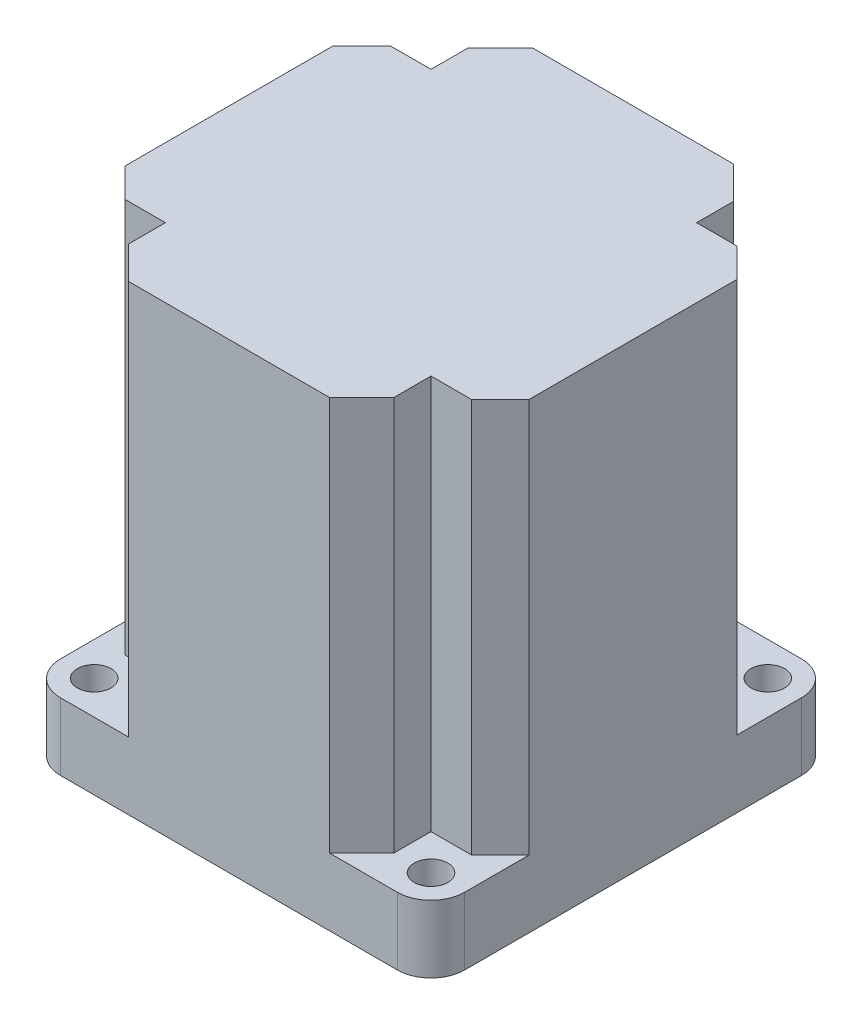
from build123d import *

# Parameters (mm, degrees)
SKETCH1_R           = 1.75
SKETCH1_R_2         = 14
BOSS_EXTRUDE1_DEPTH = 7
BOSS_EXTRUDE2_DEPTH = 34
BOSS_EXTRUDE3_DEPTH = 7
CUT_EXTRUDE1_START  = -41
CUT_EXTRUDE1_DEPTH  = 41
SKETCH1_2_R         = 14
CUT_EXTRUDE2_DEPTH  = 15


with BuildPart() as part:
    # Sketch1 → Boss-Extrude1 (new body)
    with BuildSketch(Plane(origin=(0, 0, 0), x_dir=(1, 0, 0), z_dir=(0, 1, 0))):
        with BuildLine():
            Line((17.5, -21), (-17.5, -21))
            ThreePointArc((-17.5, -21), (-19.974873734, -19.974873734), (-21, -17.5))
            Line((-21, -17.5), (-21, 17.5))
            ThreePointArc((-21, 17.5), (-19.974873734, 19.974873734), (-17.5, 21))
            Line((-17.5, 21), (17.5, 21))
            ThreePointArc((17.5, 21), (19.974873734, 19.974873734), (21, 17.5))
            Line((21, 17.5), (21, -17.5))
            ThreePointArc((21, -17.5), (19.974873734, -19.974873734), (17.5, -21))
        make_face()
        with Locations((-17.5, -17.5)):
            Circle(SKETCH1_R, mode=Mode.SUBTRACT)
        with Locations((-17.5, 17.5)):
            Circle(SKETCH1_R, mode=Mode.SUBTRACT)
        with Locations((17.5, -17.5)):
            Circle(SKETCH1_R, mode=Mode.SUBTRACT)
        with Locations((17.5, 17.5)):
            Circle(SKETCH1_R, mode=Mode.SUBTRACT)
        Circle(SKETCH1_R_2, mode=Mode.SUBTRACT)
    extrude(amount=BOSS_EXTRUDE1_DEPTH)

    # Sketch2 → Boss-Extrude2 (add)
    with BuildSketch(Plane(origin=(0, 7, 0), x_dir=(1, 0, 0), z_dir=(0, 1, 0))):
        with BuildLine():
            Line((21, -17.5), (21, 17.5))
            ThreePointArc((21, 17.5), (19.974873734, 19.974873734), (17.5, 21))
            Line((17.5, 21), (-17.5, 21))
            ThreePointArc((-17.5, 21), (-19.974873734, 19.974873734), (-21, 17.5))
            Line((-21, 17.5), (-21, -17.5))
            ThreePointArc((-21, -17.5), (-19.974873734, -19.974873734), (-17.5, -21))
            Line((-17.5, -21), (17.5, -21))
            ThreePointArc((17.5, -21), (19.974873734, -19.974873734), (21, -17.5))
        make_face()
    extrude(amount=BOSS_EXTRUDE2_DEPTH)

    # Sketch3 → Boss-Extrude3 (add)
    with BuildSketch(Plane(origin=(0, 41, 0), x_dir=(1, 0, 0), z_dir=(0, 1, 0))):
        with BuildLine():
            Line((17.5, 21), (-17.5, 21))
            ThreePointArc((-17.5, 21), (-19.974873734, 19.974873734), (-21, 17.5))
            Line((-21, 17.5), (-21, -17.5))
            ThreePointArc((-21, -17.5), (-19.974873734, -19.974873734), (-17.5, -21))
            Line((-17.5, -21), (17.5, -21))
            ThreePointArc((17.5, -21), (19.974873734, -19.974873734), (21, -17.5))
            Line((21, -17.5), (21, 17.5))
            ThreePointArc((21, 17.5), (19.974873734, 19.974873734), (17.5, 21))
        make_face()
    extrude(amount=BOSS_EXTRUDE3_DEPTH)

    # Sketch4 → Cut-Extrude1 (cut)
    with BuildSketch(Plane(origin=(0, 48, 0), x_dir=(1, 0, 0), z_dir=(0, 1, 0)).offset(CUT_EXTRUDE1_START)):
        with BuildLine():
            Line((-13.8, 13.8), (-18, 13.8))
            Line((-18, 13.8), (-21, 10.8))
            Line((-21, 10.8), (-21, 17.5))
            ThreePointArc((-21, 17.5), (-19.974873734, 19.974873734), (-17.5, 21))
            Line((-17.5, 21), (-10.45, 21))
            Line((-10.45, 21), (-13.8, 17.65))
            Line((-13.8, 17.65), (-13.8, 13.8))
        make_face()
        with BuildLine():
            Line((17.5, 21), (10.45, 21))
            Line((10.45, 21), (13.8, 17.65))
            Line((13.8, 17.65), (13.8, 13.8))
            Line((13.8, 13.8), (18, 13.8))
            Line((18, 13.8), (21, 10.8))
            Line((21, 10.8), (21, 17.5))
            ThreePointArc((21, 17.5), (19.974873734, 19.974873734), (17.5, 21))
        make_face()
        with BuildLine():
            Line((-17.5, -21), (-10.45, -21))
            Line((-10.45, -21), (-13.8, -17.65))
            Line((-13.8, -17.65), (-13.8, -13.8))
            Line((-13.8, -13.8), (-18, -13.8))
            Line((-18, -13.8), (-21, -10.8))
            Line((-21, -10.8), (-21, -17.5))
            ThreePointArc((-21, -17.5), (-19.974873734, -19.974873734), (-17.5, -21))
        make_face()
        with BuildLine():
            Line((21, -17.5), (21, -10.8))
            Line((21, -10.8), (18, -13.8))
            Line((18, -13.8), (13.8, -13.8))
            Line((13.8, -13.8), (13.8, -17.65))
            Line((13.8, -17.65), (10.45, -21))
            Line((10.45, -21), (17.5, -21))
            ThreePointArc((17.5, -21), (19.974873734, -19.974873734), (21, -17.5))
        make_face()
    extrude(amount=CUT_EXTRUDE1_DEPTH, mode=Mode.SUBTRACT)

    # Sketch1_2 → Cut-Extrude2 (cut)
    with BuildSketch(Plane(origin=(0, 0, 0), x_dir=(1, 0, 0), z_dir=(0, 1, 0))):
        Circle(SKETCH1_2_R)
    extrude(amount=CUT_EXTRUDE2_DEPTH, mode=Mode.SUBTRACT)


solid = part.part
